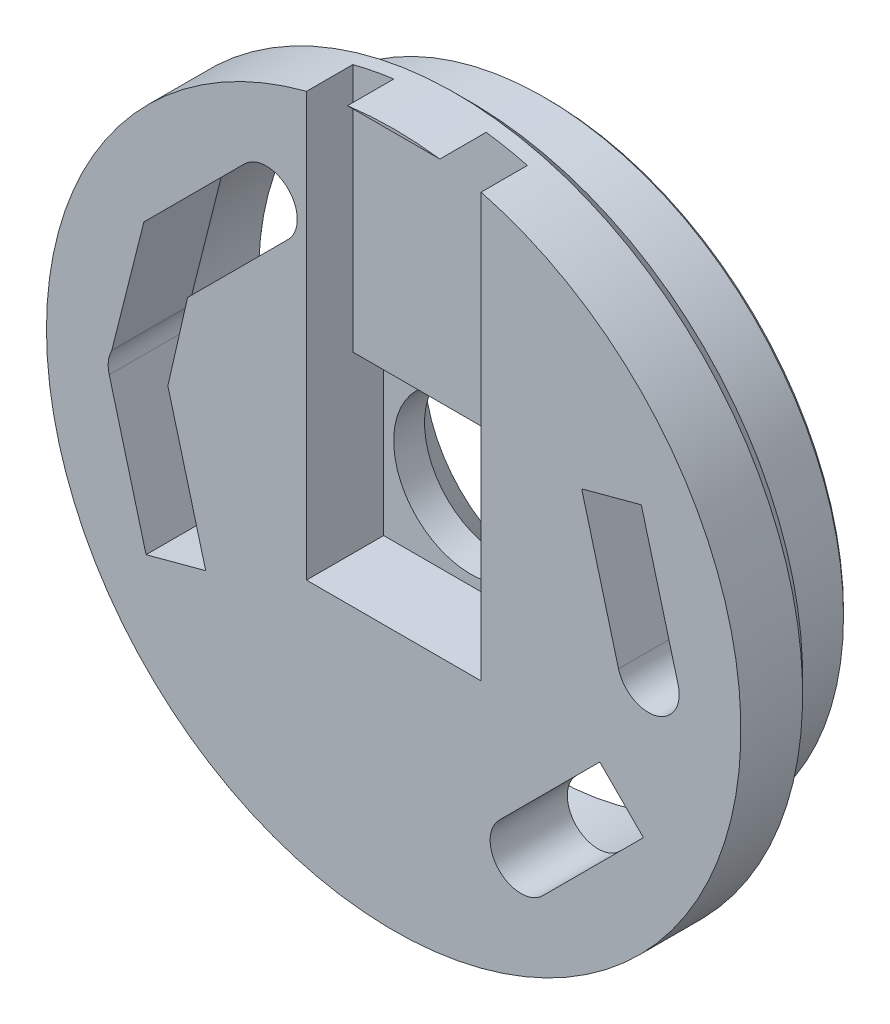
from build123d import *

# Parameters (mm, degrees)
SKETCH1_R           = 9.8
SKETCH1_R_2         = 5
BOSS_EXTRUDE1_DEPTH = 10
SKETCH2_W           = 11.3
SKETCH2_H           = 11.3
CUT_EXTRUDE1_DEPTH  = 5
SKETCH3_W           = 11.313408722
SKETCH3_H           = 4.707055676
CUT_EXTRUDE2_DEPTH  = 3
SKETCH4_W           = 5.404805584
SKETCH4_H           = 18.076359344
SKETCH4_W_2         = 5.663408722
SKETCH4_H_2         = 17.947057775
CUT_EXTRUDE3_DEPTH  = 3
CHAMFER1_SIZE       = 3
SKETCH5_R           = 22.5
SKETCH5_R_2         = 9.8
BOSS_EXTRUDE2_DEPTH = 1
SKETCH6_R           = 11.25
SKETCH6_R_2         = 9.8
BOSS_EXTRUDE3_DEPTH = 5
SKETCH7_R           = 19.4
SKETCH7_R_2         = 18.75
BOSS_EXTRUDE4_DEPTH = 5
CHAMFER2_SIZE       = 0.25
SKETCH9_R           = 22.5
SKETCH9_R_2         = 9.8
BOSS_EXTRUDE5_DEPTH = 4
SKETCH10_W          = 11.313408722
SKETCH10_H          = 16.65
CUT_EXTRUDE5_DEPTH  = 3
CUT_EXTRUDE4_DEPTH  = 33.210246817
CIRPATTERN1_COUNT   = 6
SKETCH12_W          = 2.936696108
SKETCH12_H          = 13.215132487
SKETCH12_W_2        = 3.332020584
SKETCH12_H_2        = 13.328082337
BOSS_EXTRUDE6_DEPTH = 3
CHAMFER3_SIZE       = 1
CUT_EXTRUDE6_DEPTH  = 10
BOSS_EXTRUDE7_DEPTH = 2
BOSS_EXTRUDE8_DEPTH = 5
BOSS_EXTRUDE9_DEPTH = 5


with BuildPart() as part:
    # Sketch1 → Boss-Extrude1 (new body)
    with BuildSketch(Plane.XY):
        Circle(SKETCH1_R)
        Circle(SKETCH1_R_2, mode=Mode.SUBTRACT)
    extrude(amount=BOSS_EXTRUDE1_DEPTH)

    # Sketch2 → Cut-Extrude1 (cut)
    with BuildSketch(Plane.XY.offset(10)):
        Rectangle(SKETCH2_W, SKETCH2_H)
    extrude(amount=-CUT_EXTRUDE1_DEPTH, mode=Mode.SUBTRACT)

    # Sketch3 → Cut-Extrude2 (cut)
    with BuildSketch(Plane.XY.offset(10)):
        with Locations((0.006704361, 8.003527838)):
            Rectangle(SKETCH3_W, SKETCH3_H)
    extrude(amount=-CUT_EXTRUDE2_DEPTH, mode=Mode.SUBTRACT)

    # Sketch4 → Cut-Extrude3 (cut)
    with BuildSketch(Plane.XY.offset(10)):
        with Locations((-10.5897985, 0)):
            Rectangle(SKETCH4_W, SKETCH4_H)
        with Locations((10.615658814, 0.064650784)):
            Rectangle(SKETCH4_W_2, SKETCH4_H_2)
    extrude(amount=-CUT_EXTRUDE3_DEPTH, mode=Mode.SUBTRACT)

    # Chamfer1
    chamfer1_edges = [part.edges().sort_by_distance(p)[0] for p in [
        (-5, 0, 0),
    ]]
    chamfer(chamfer1_edges, length=CHAMFER1_SIZE)

    # Sketch5 → Boss-Extrude2 (add)
    with BuildSketch(Plane(origin=(0, 0, 5), x_dir=(-1, 0, 0), z_dir=(0, 0, -1))):
        Circle(SKETCH5_R)
        Circle(SKETCH5_R_2, mode=Mode.SUBTRACT)
    extrude(amount=-BOSS_EXTRUDE2_DEPTH)

    # Sketch6 → Boss-Extrude3 (add)
    with BuildSketch(Plane(origin=(0, 0, 5), x_dir=(-1, 0, 0), z_dir=(0, 0, -1))):
        with Locations(Location((0, 0, 0), (0, 0, 180))):
            Circle(SKETCH6_R)
        Circle(SKETCH6_R_2, mode=Mode.SUBTRACT)
    extrude(amount=BOSS_EXTRUDE3_DEPTH)

    # Sketch7 → Boss-Extrude4 (add)
    with BuildSketch(Plane(origin=(0, 0, 5), x_dir=(-1, 0, 0), z_dir=(0, 0, -1))):
        with Locations(Location((0, 0, 0), (0, 0, 180))):
            Circle(SKETCH7_R)
        with Locations(Location((0, 0, 0), (0, 0, 180))):
            Circle(SKETCH7_R_2, mode=Mode.SUBTRACT)
    extrude(amount=BOSS_EXTRUDE4_DEPTH)

    # Chamfer2
    chamfer2_edges = [part.edges().sort_by_distance(p)[0] for p in [
        (-19.4, 0, 0),
    ]]
    chamfer(chamfer2_edges, length=CHAMFER2_SIZE)

    # Sketch9 → Boss-Extrude5 (add)
    with BuildSketch(Plane.XY.offset(6)):
        with Locations(Location((0, 0, 0), (0, 0, 180))):
            Circle(SKETCH9_R)
        Circle(SKETCH9_R_2, mode=Mode.SUBTRACT)
    extrude(amount=BOSS_EXTRUDE5_DEPTH)

    # Sketch10 → Cut-Extrude5 (cut)
    with BuildSketch(Plane.XY.offset(10)):
        with Locations((0.006704361, 13.975)):
            Rectangle(SKETCH10_W, SKETCH10_H)
    extrude(amount=-CUT_EXTRUDE5_DEPTH, mode=Mode.SUBTRACT)

    # Sketch8 → Cut-Extrude4 (cut, through all)
    with BuildSketch(Plane(origin=(0, 0, 5), x_dir=(-1, 0, 0), z_dir=(0, 0, -1))):
        with BuildLine():
            Line((-7.732356662, 12.357593624), (1.172643737, 14.743669758))
            Line((1.172643737, 14.743669758), (0.137372224, 18.607374314))
            Line((0.137372224, 18.607374314), (-8.767628174, 16.22129818))
            ThreePointArc((-8.767628174, 16.22129818), (-10.181844696, 13.771810146), (-7.732356662, 12.357593624))
        make_face()
    cut_extrude4 = extrude(amount=-CUT_EXTRUDE4_DEPTH, mode=Mode.SUBTRACT)

    # CirPattern1: Cut-Extrude4 ×6 about axis
    cirpattern1_axis = Axis((0, 0, 0), (0, 0, 1))
    for i in range(1, CIRPATTERN1_COUNT):
        add(cut_extrude4.rotate(cirpattern1_axis, i * 360 / CIRPATTERN1_COUNT), mode=Mode.SUBTRACT)

    # Sketch12 → Boss-Extrude6 (add)
    with BuildSketch(Plane.XY.offset(7)):
        with Locations((-8.471238773, 0.2258997)):
            Rectangle(SKETCH12_W, SKETCH12_H)
        with Locations((8.555951161, 0.282374626)):
            Rectangle(SKETCH12_W_2, SKETCH12_H_2)
    extrude(amount=BOSS_EXTRUDE6_DEPTH)

    # Chamfer3
    chamfer3_edges = [part.edges().sort_by_distance(p)[0] for p in [
        (22.5, 0, 5),
    ]]
    chamfer(chamfer3_edges, length=CHAMFER3_SIZE)

    # Sketch13 → Cut-Extrude6 (cut)
    with BuildSketch(Plane.XY.offset(10)):
        Polygon((-16.183144966, 9.184719321), (-18.500019366, -1.9936e-05), (-14.638921299, 0.732314676), (-13.354714423, 6.356295613), align=None)
    extrude(amount=-CUT_EXTRUDE6_DEPTH, mode=Mode.SUBTRACT)

    # Sketch14 → Boss-Extrude7 (add)
    with BuildSketch(Plane.XY.offset(7)):
        Polygon((-0.137372224, 18.607374314), (5.663408722, 17.053067256), (5.663408722, 12.911963875), (-1.172643737, 14.743669758), align=None)
    extrude(amount=-BOSS_EXTRUDE7_DEPTH)

    # Sketch15 → Boss-Extrude8 (add)
    with BuildSketch(Plane.XY.offset(10)):
        with BuildLine():
            Line((8.767628174, 16.22129818), (5.663408722, 17.053067256))
            Line((5.663408722, 17.053067256), (5.663408722, 12.911963875))
            Line((5.663408722, 12.911963875), (7.732356662, 12.357593624))
            ThreePointArc((7.732356662, 12.357593624), (10.181844696, 13.771810146), (8.767628174, 16.22129818))
        make_face()
    extrude(amount=-BOSS_EXTRUDE8_DEPTH)

    # Sketch16 → Boss-Extrude9 (add)
    with BuildSketch(Plane.XY.offset(10)):
        with BuildLine():
            Line((-8.767628174, -16.22129818), (0.137372224, -18.607374314))
            Line((0.137372224, -18.607374314), (1.172643737, -14.743669758))
            Line((1.172643737, -14.743669758), (-7.732356662, -12.357593624))
            ThreePointArc((-7.732356662, -12.357593624), (-10.181844696, -13.771810146), (-8.767628174, -16.22129818))
        make_face()
    extrude(amount=-BOSS_EXTRUDE9_DEPTH)


solid = part.part
